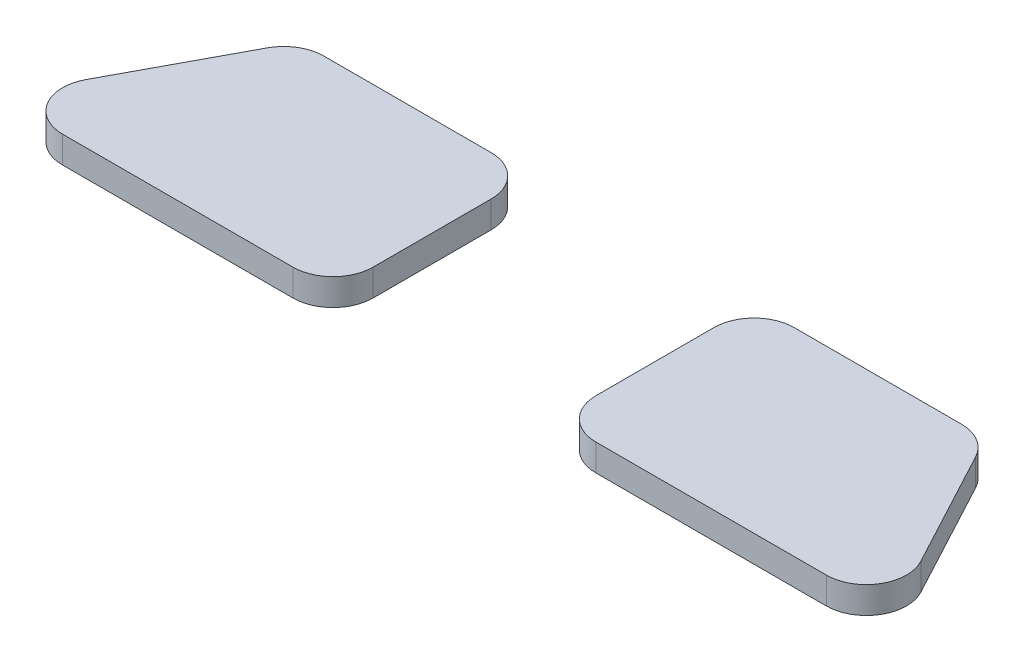
from build123d import *

# Parameters (mm, degrees)
EXTRUDE_1_DEPTH   = 2
EXTRUDE_1_2_DEPTH = 2


with BuildPart() as part:
    # 草图1 → 凸台-拉伸1 (new body)
    with BuildSketch(Plane(origin=(0, 0, 0), x_dir=(1, 0, 0), z_dir=(0, 1, 0))):
        with BuildLine():
            Line((1.797714334, 0), (14.29, 0))
            ThreePointArc((14.29, 0), (16.411320344, -0.878679656), (17.29, -3))
            Line((17.29, -3), (17.29, -11.81))
            ThreePointArc((17.29, -11.81), (16.411320344, -13.931320344), (14.29, -14.81))
            Line((14.29, -14.81), (-2.913642857, -14.81))
            ThreePointArc((-2.913642857, -14.81), (-5.486986201, -13.352045406), (-5.559117711, -10.395269356))
            Line((-5.559117711, -10.395269356), (-0.84776052, -1.585269356))
            ThreePointArc((-0.84776052, -1.585269356), (0.255668929, -0.426656656), (1.797714334, 0))
        make_face()
    extrude(amount=EXTRUDE_1_DEPTH)


with BuildPart() as body_2:
    # 草图1 → Extrude 1 2 (new body)
    with BuildSketch(Plane(origin=(0, 0, 0), x_dir=(1, 0, 0), z_dir=(0, 1, 0))):
        with BuildLine():
            Line((33.929771652, -3), (33.929771652, -11.81))
            ThreePointArc((33.929771652, -11.81), (34.808451309, -13.931320344), (36.929771652, -14.81))
            Line((36.929771652, -14.81), (54.133414509, -14.81))
            ThreePointArc((54.133414509, -14.81), (56.706757853, -13.352045406), (56.778889363, -10.395269356))
            Line((56.778889363, -10.395269356), (52.067532172, -1.585269356))
            ThreePointArc((52.067532172, -1.585269356), (50.964102723, -0.426656656), (49.422057318, 0))
            Line((49.422057318, 0), (36.929771652, 0))
            ThreePointArc((36.929771652, 0), (34.808451309, -0.878679656), (33.929771652, -3))
        make_face()
    extrude(amount=EXTRUDE_1_2_DEPTH)


solid = Compound([part.part, body_2.part])
